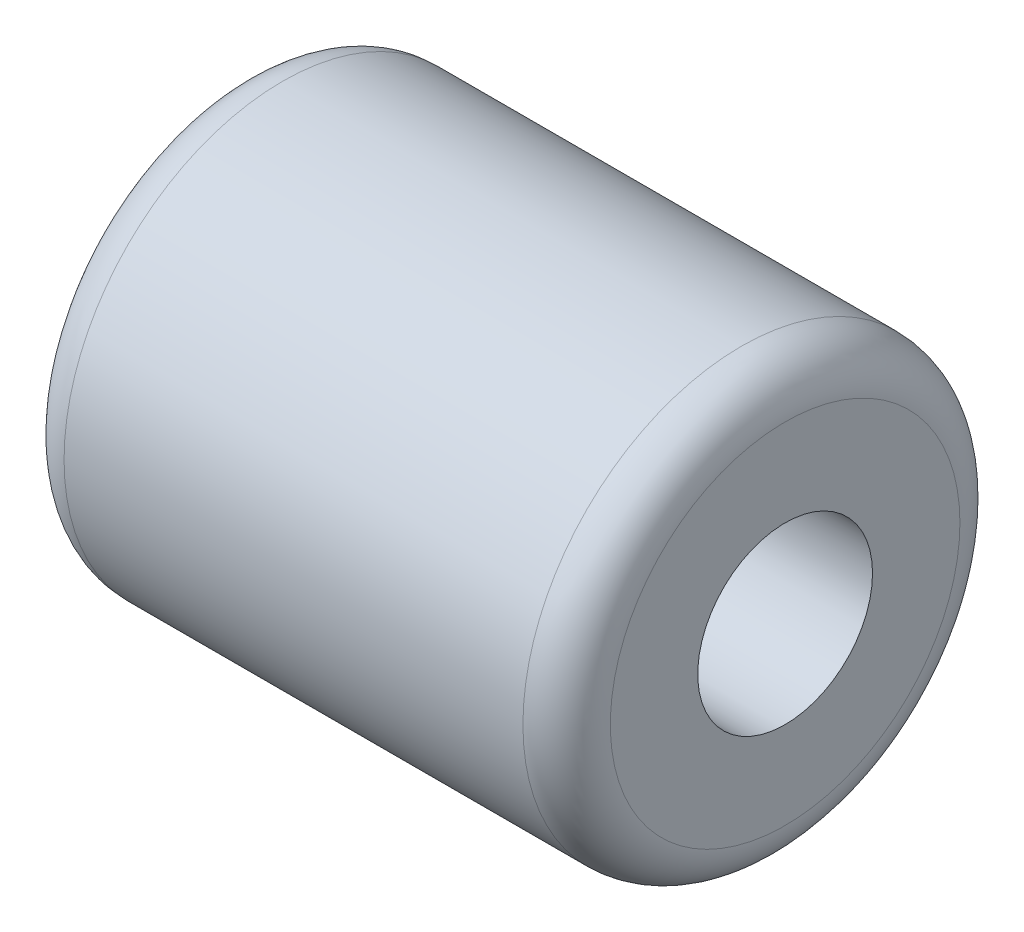
from build123d import *

# Parameters (mm, degrees)
SKETCH1_R           = 10
BOSS_EXTRUDE1_DEPTH = 25
SKETCH2_R           = 4
CUT_EXTRUDE1_DEPTH  = 26
FILLET1_R           = 2


with BuildPart() as part:
    # Sketch1 → Boss-Extrude1 (new body)
    with BuildSketch(Plane(origin=(0, 0, 0), x_dir=(0, 0, -1), z_dir=(1, 0, 0))):
        Circle(SKETCH1_R)
    extrude(amount=BOSS_EXTRUDE1_DEPTH)

    # Sketch2 → Cut-Extrude1 (cut, through all)
    with BuildSketch(Plane(origin=(25, 0, 0), x_dir=(0, 0, -1), z_dir=(1, 0, 0))):
        Circle(SKETCH2_R)
    extrude(amount=-CUT_EXTRUDE1_DEPTH, mode=Mode.SUBTRACT)

    # Fillet1
    fillet1_edges = [part.edges().sort_by_distance(p)[0] for p in [
        (0, 0, 10),
        (25, 0, 10),
    ]]
    fillet(fillet1_edges, radius=FILLET1_R)


solid = part.part
